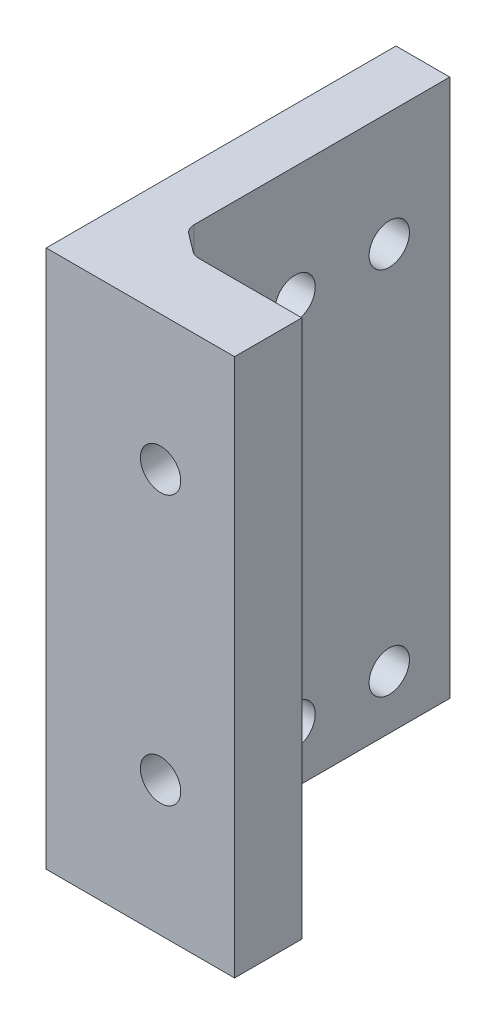
from build123d import *

# Parameters (mm, degrees)
SKETCH1_W                = 4
SKETCH1_H                = 40
BOSS_EXTRUDE2_DEPTH      = 20
BOSS_EXTRUDE2_DEPTH_BACK = 4
SKETCH3_R                = 1.5
CUT_EXTRUDE1_DEPTH       = 29.565713714
SKETCH4_W                = 3
SKETCH4_H                = 40
BOSS_EXTRUDE3_DEPTH      = 10
SKETCH5_R                = 1.5
CUT_EXTRUDE2_DEPTH       = 39.288379438
SKETCH8_W                = 14
SKETCH8_H                = 40
SKETCH8_R                = 1.5
BOSS_EXTRUDE4_DEPTH      = 2
BOSS_EXTRUDE5_DEPTH      = 40
FILLET3_R                = 1


with BuildPart() as part:
    # Sketch1 → Boss-Extrude2 (new, two sides)
    with BuildSketch(Plane.XY) as boss_extrude2_sk:
        with Locations((13, 0)):
            Rectangle(SKETCH1_W, SKETCH1_H)
    extrude(amount=BOSS_EXTRUDE2_DEPTH)
    extrude(boss_extrude2_sk.sketch, amount=-BOSS_EXTRUDE2_DEPTH_BACK)

    # Sketch3 → Cut-Extrude1 (cut, through all)
    with BuildSketch(Plane(origin=(15, 0, 0), x_dir=(0, 0, -1), z_dir=(1, 0, 0))):
        with Locations((-7.5, -16)):
            Circle(SKETCH3_R)
        with Locations((-7.5, 11.5)):
            Circle(SKETCH3_R)
        with Locations((-0.5, 11.5)):
            Circle(SKETCH3_R)
        with Locations((-0.5, -16)):
            Circle(SKETCH3_R)
    extrude(amount=-CUT_EXTRUDE1_DEPTH, mode=Mode.SUBTRACT)

    # Sketch4 → Boss-Extrude3 (add)
    with BuildSketch(Plane(origin=(15, 0, 0), x_dir=(0, 0, -1), z_dir=(1, 0, 0))):
        with Locations((-18.5, 0)):
            Rectangle(SKETCH4_W, SKETCH4_H)
    extrude(amount=BOSS_EXTRUDE3_DEPTH)

    # Sketch5 → Cut-Extrude2 (cut, through all)
    with BuildSketch(Plane(origin=(0, 0, 17), x_dir=(-1, 0, 0), z_dir=(0, 0, -1))):
        with Locations(Location((-19.5, -10, 0), (0, 0, 90))):
            Circle(SKETCH5_R)
        with Locations(Location((-19.5, 10, 0), (0, 0, 90))):
            Circle(SKETCH5_R)
    extrude(amount=-CUT_EXTRUDE2_DEPTH, mode=Mode.SUBTRACT)

    # Sketch8 → Boss-Extrude4 (add)
    with BuildSketch(Plane.XY.offset(20)):
        with Locations((18, 0)):
            Rectangle(SKETCH8_W, SKETCH8_H)
        with Locations(Location((19.5, 10, 0), (0, 0, 90))):
            Circle(SKETCH8_R, mode=Mode.SUBTRACT)
        with Locations(Location((19.5, -10, 0), (0, 0, 90))):
            Circle(SKETCH8_R, mode=Mode.SUBTRACT)
    extrude(amount=BOSS_EXTRUDE4_DEPTH)

    # Sketch9 → Boss-Extrude5 (add)
    with BuildSketch(Plane.XZ.offset(20)):
        Polygon((17, 17), (15, 17), (15, 15.5), align=None)
    extrude(amount=-BOSS_EXTRUDE5_DEPTH)

    # Fillet3
    fillet3_edges = [part.edges().sort_by_distance(p)[0] for p in [
        (15, 0, 15.5),
        (17, 0, 17),
    ]]
    fillet(fillet3_edges, radius=FILLET3_R)


solid = part.part
